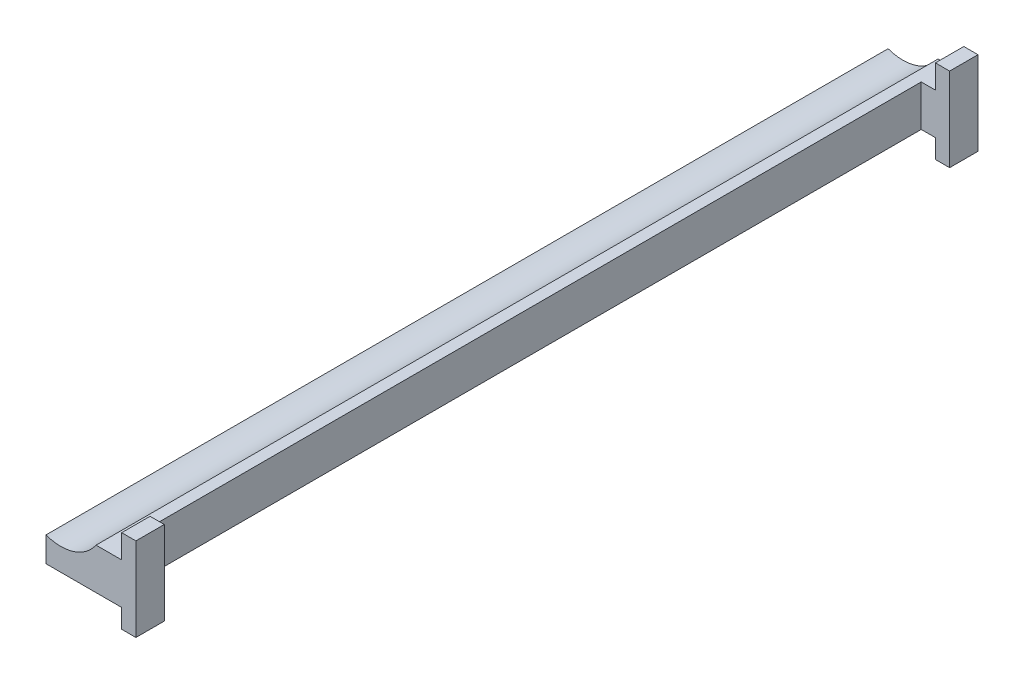
from build123d import *

# Parameters (mm, degrees)
BOSS_EXTRUDE1_DEPTH = 890
SKETCH4_W           = 830
SKETCH4_H           = 88.442264386
CUT_EXTRUDE1_DEPTH  = 30


with BuildPart() as part:
    # Sketch1 → Boss-Extrude1 (new body)
    with BuildSketch(Plane.XY):
        with BuildLine():
            ThreePointArc((-282.415201489, 0.868106525), (-253.025149144, 0.266679613), (-229.534634399, 17.939613952))
            Line((-229.534634399, 17.939613952), (-202.415201489, 17.939613952))
            Line((-202.415201489, 17.939613952), (-202.415201489, 42.879994244))
            Line((-202.415201489, 42.879994244), (-187.415201489, 42.879994244))
            Line((-187.415201489, 42.879994244), (-187.415201489, -45.562270142))
            Line((-187.415201489, -45.562270142), (-202.415201489, -45.562270142))
            Line((-202.415201489, -45.562270142), (-202.415201489, -25.562270142))
            Line((-202.415201489, -25.562270142), (-282.415201489, -25.562270142))
            Line((-282.415201489, -25.562270142), (-282.415201489, 0.868106525))
        make_face()
    extrude(amount=-BOSS_EXTRUDE1_DEPTH)

    # Sketch4 → Cut-Extrude1 (cut)
    with BuildSketch(Plane(origin=(-187.415201489, 0, 0), x_dir=(0, 0, -1), z_dir=(1, 0, 0))):
        with Locations((445, -1.341137949)):
            Rectangle(SKETCH4_W, SKETCH4_H)
    extrude(amount=-CUT_EXTRUDE1_DEPTH, mode=Mode.SUBTRACT)


solid = part.part
